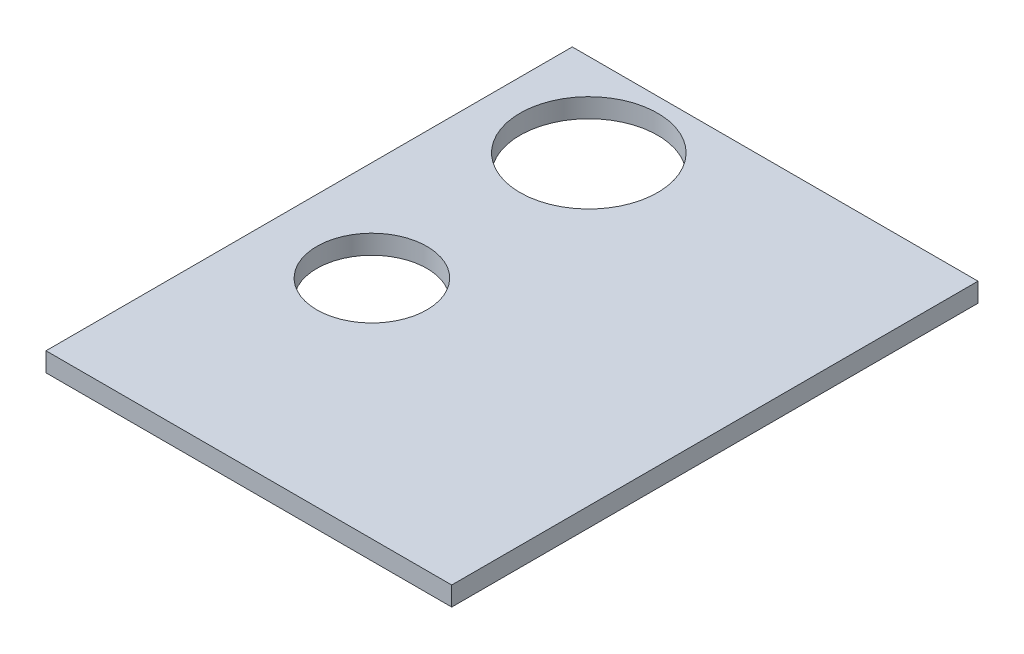
from build123d import *

# Parameters (mm, degrees)
ESQUISSE1_W             = 84.803189305
ESQUISSE1_H             = 110
BOSS_EXTRU_1_DEPTH      = 4
ESQUISSE2_R             = 14.383210578
ESQUISSE2_R_2           = 11.5
ENL_V_MAT_EXTRU_1_DEPTH = 5


with BuildPart() as part:
    # Esquisse1 → Boss.-Extru.1 (new body)
    with BuildSketch(Plane(origin=(0, 0, 0), x_dir=(1, 0, 0), z_dir=(0, 1, 0))):
        with Locations((42.401594653, -55)):
            Rectangle(ESQUISSE1_W, ESQUISSE1_H)
    extrude(amount=BOSS_EXTRU_1_DEPTH)

    # Esquisse2 → Enlèv. mat.-Extru.1 (cut, through all)
    with BuildSketch(Plane(origin=(0, 4, 0), x_dir=(1, 0, 0), z_dir=(0, 1, 0))):
        with Locations((20.904686025, -17.448336439)):
            Circle(ESQUISSE2_R)
        with Locations((20.904686025, -62.790814853)):
            Circle(ESQUISSE2_R_2)
    extrude(amount=-ENL_V_MAT_EXTRU_1_DEPTH, mode=Mode.SUBTRACT)


solid = part.part
